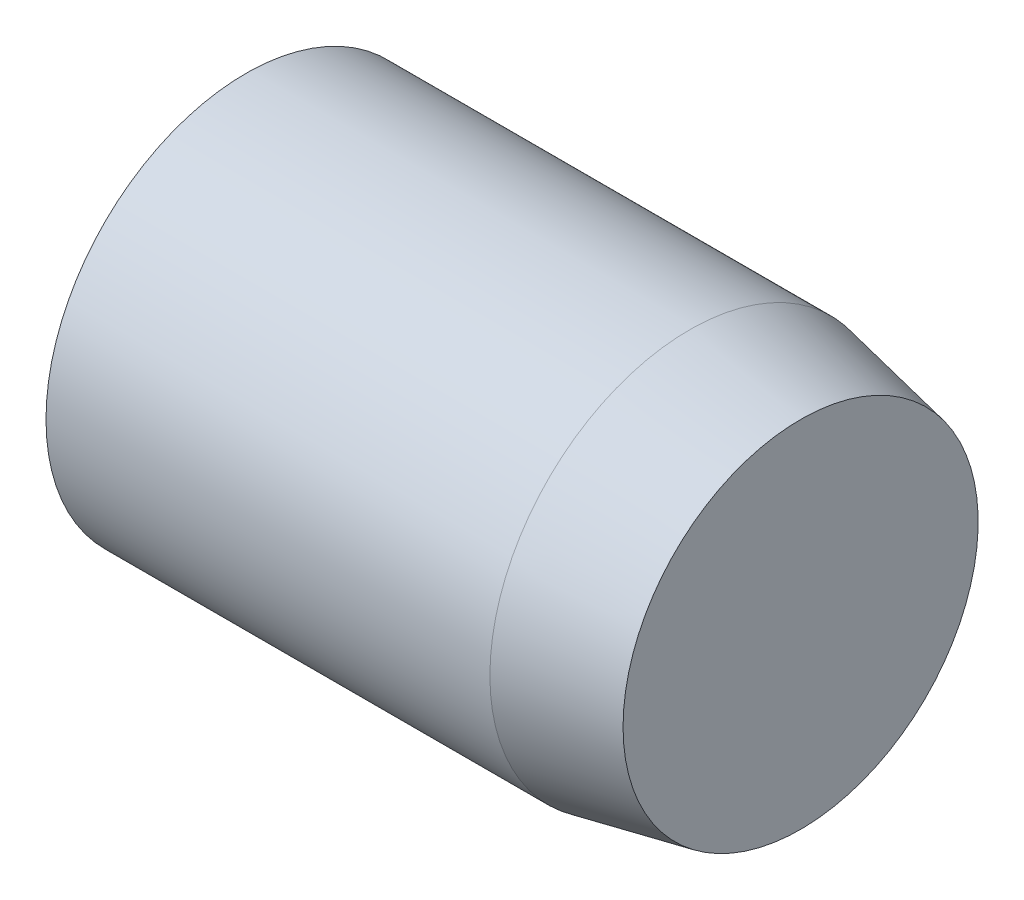
from build123d import *


with BuildPart() as part:
    # Sketch1 → Revolve1 (revolve)
    with BuildSketch(Plane(origin=(0, 0, 0), x_dir=(1, 0, 0), z_dir=(0, 1, 0))):
        Polygon((0, 0), (12.5, 0), (12.5, 4), (10, 4.5), (0, 4.5), align=None)
    revolve(axis=Axis((0, 0, 0), (1, 0, 0)))


solid = part.part
